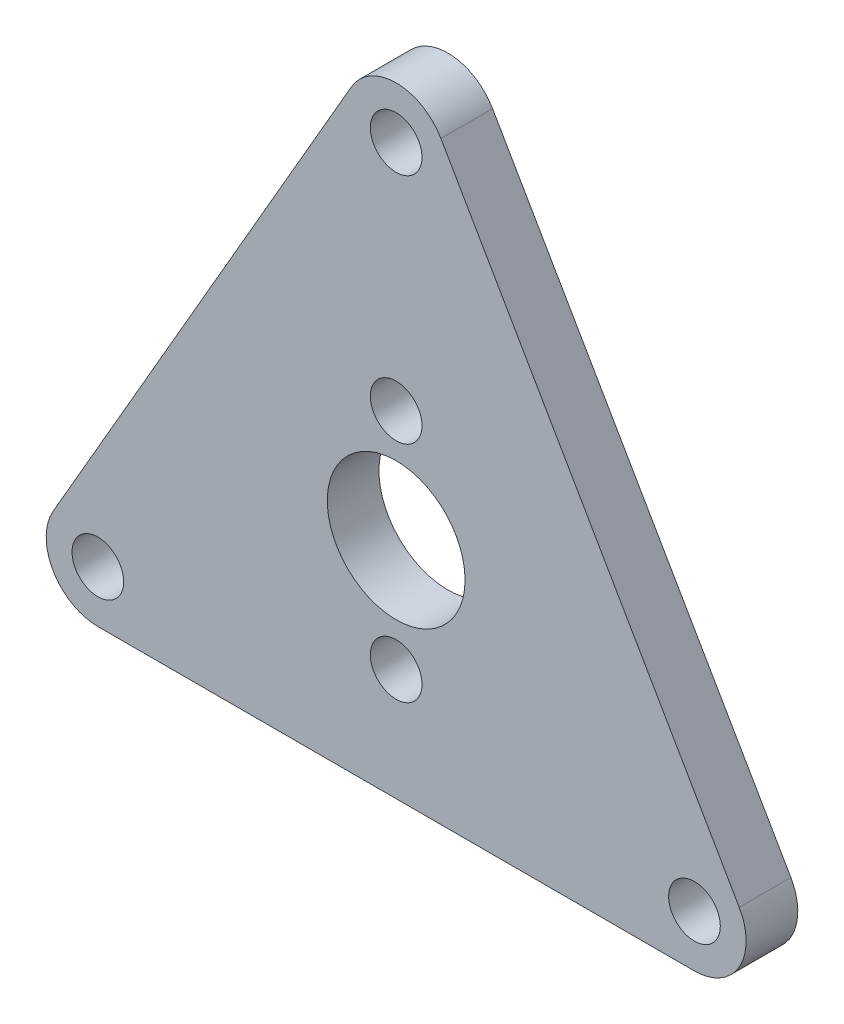
from build123d import *

# Parameters (mm, degrees)
SKETCH_1_R      = 1.5
SKETCH_1_R_2    = 4
EXTRUDE_1_DEPTH = 3


with BuildPart() as part:
    # 草图1 → 凸台-拉伸1 (new body)
    with BuildSketch(Plane.XY):
        with BuildLine():
            Line((-2.598076211, 21.5), (-19.918584287, -8.5))
            ThreePointArc((-19.918584287, -8.5), (-19.918584287, -11.5), (-17.320508076, -13))
            Line((-17.320508076, -13), (17.320508076, -13))
            ThreePointArc((17.320508076, -13), (19.918584287, -11.5), (19.918584287, -8.5))
            Line((19.918584287, -8.5), (2.598076211, 21.5))
            ThreePointArc((2.598076211, 21.5), (0, 23), (-2.598076211, 21.5))
        make_face()
        with Locations((-17.320508076, -10)):
            Circle(SKETCH_1_R, mode=Mode.SUBTRACT)
        with Locations((0, 20)):
            Circle(SKETCH_1_R, mode=Mode.SUBTRACT)
        with Locations((17.320508076, -10)):
            Circle(SKETCH_1_R, mode=Mode.SUBTRACT)
        Circle(SKETCH_1_R_2, mode=Mode.SUBTRACT)
        with Locations((0, 6.5)):
            Circle(SKETCH_1_R, mode=Mode.SUBTRACT)
        with Locations((0, -6.5)):
            Circle(SKETCH_1_R, mode=Mode.SUBTRACT)
    extrude(amount=EXTRUDE_1_DEPTH)


solid = part.part
